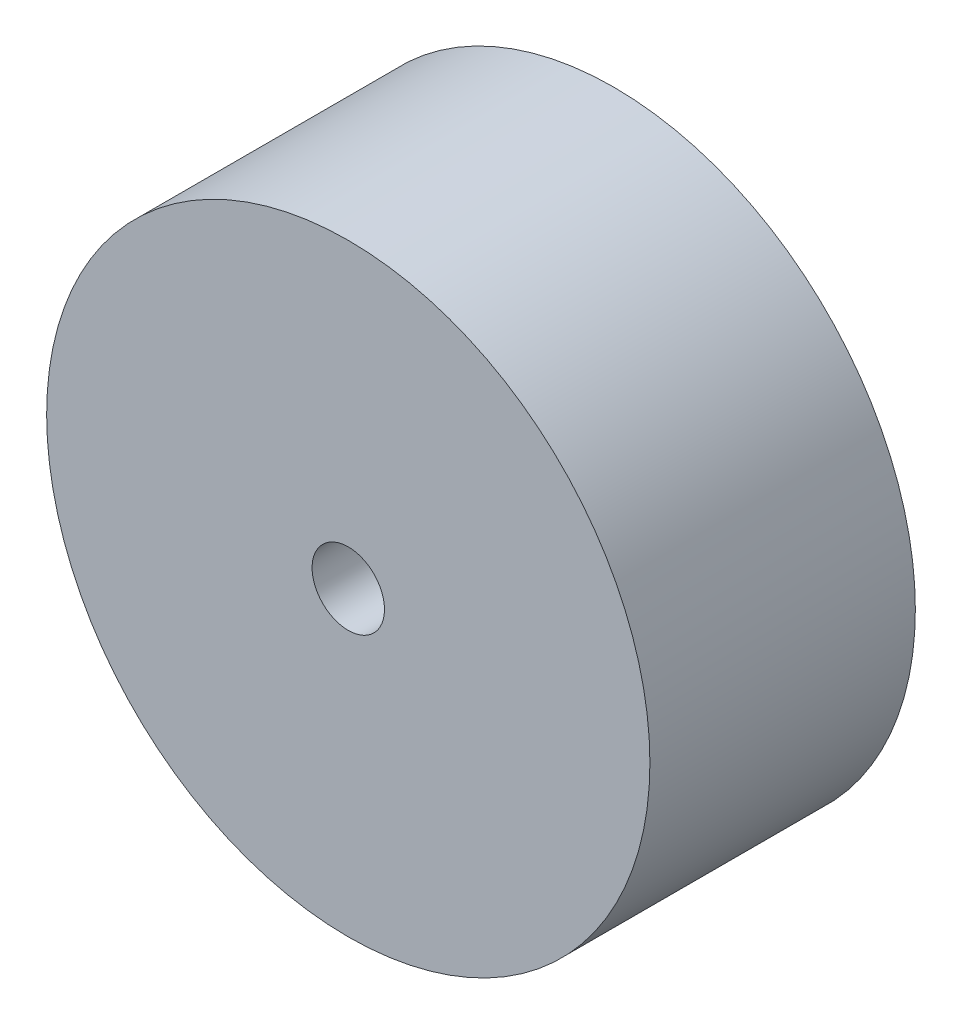
from build123d import *

# Parameters (mm, degrees)
SKETCH_1_R      = 5
SKETCH_1_R_2    = 0.6
EXTRUDE_1_DEPTH = 4.4


with BuildPart() as part:
    # 草图1 → 凸台-拉伸1 (new body)
    with BuildSketch(Plane.XY):
        Circle(SKETCH_1_R)
        Circle(SKETCH_1_R_2, mode=Mode.SUBTRACT)
    extrude(amount=EXTRUDE_1_DEPTH)


solid = part.part
